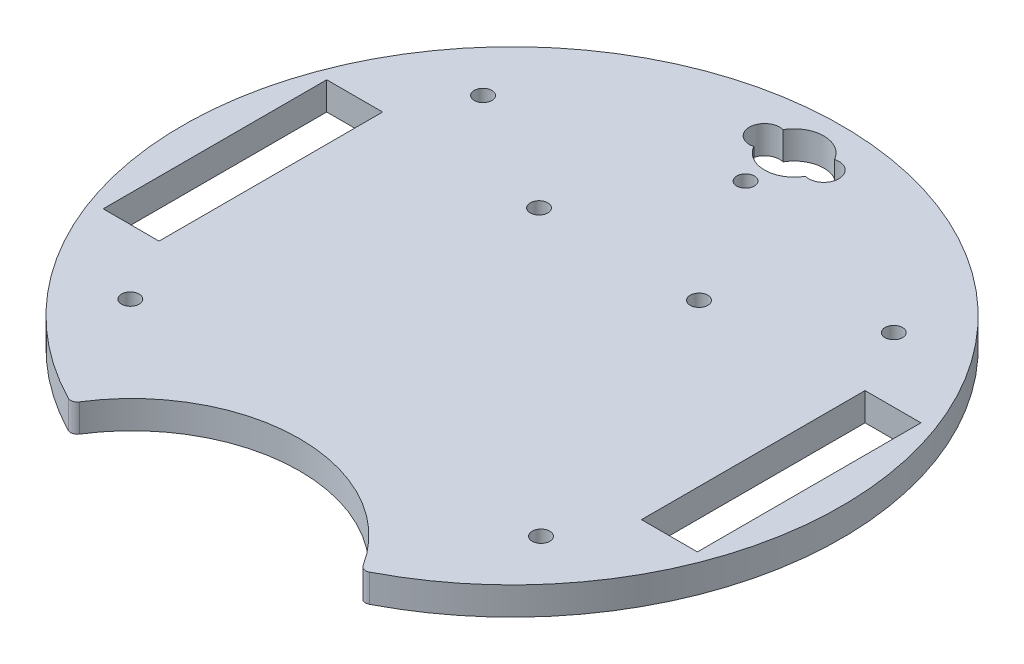
from build123d import *

# Parameters (mm, degrees)
SKETCH1_R           = 2
SKETCH1_W           = 12.7
SKETCH1_H           = 50.8
BOSS_EXTRUDE3_DEPTH = 6.35


with BuildPart() as part:
    # Sketch1 → Boss-Extrude3 (new body)
    with BuildSketch(Plane(origin=(0, 0, 0), x_dir=(1, 0, 0), z_dir=(0, 1, 0))):
        with BuildLine():
            ThreePointArc((34.194833578, -66.63583839), (33.11372382, -66.748004461), (32.240681933, -66.10056535))
            ThreePointArc((32.240681933, -66.10056535), (0, -48.302004425), (-32.240681933, -66.10056535))
            ThreePointArc((-32.240681933, -66.10056535), (-33.11372382, -66.748004461), (-34.194833578, -66.63583839))
            ThreePointArc((-34.194833578, -66.63583839), (0, 74.897407173), (34.194833578, -66.63583839))
        make_face()
        with Locations((0, 53.061187965)):
            Circle(SKETCH1_R, mode=Mode.SUBTRACT)
        with Locations((18.178952795, 24.310551096)):
            Circle(SKETCH1_R, mode=Mode.SUBTRACT)
        with Locations((46.663733983, 40.081231883)):
            Circle(SKETCH1_R, mode=Mode.SUBTRACT)
        with Locations((46.663733983, -40.081231883)):
            Circle(SKETCH1_R, mode=Mode.SUBTRACT)
        with Locations((-46.663733983, -40.081231883)):
            Circle(SKETCH1_R, mode=Mode.SUBTRACT)
        with Locations((-18.178952795, 24.310551096)):
            Circle(SKETCH1_R, mode=Mode.SUBTRACT)
        with Locations((-46.663733983, 40.081231883)):
            Circle(SKETCH1_R, mode=Mode.SUBTRACT)
        with Locations((61.164123727, 0)):
            Rectangle(SKETCH1_W, SKETCH1_H, mode=Mode.SUBTRACT)
        with Locations((-61.164123727, 0)):
            Rectangle(SKETCH1_W, SKETCH1_H, mode=Mode.SUBTRACT)
        with BuildLine():
            ThreePointArc((-5.853899988, 60.78531778), (0.003726822, 57.376699875), (5.857575472, 60.791802193))
            ThreePointArc((5.857575472, 60.791802193), (10.16, 64.107698843), (5.857575472, 67.423595493))
            ThreePointArc((5.857575472, 67.423595493), (0.003726822, 70.838697812), (-5.853899988, 67.430079907))
            ThreePointArc((-5.853899988, 67.430079907), (-10.167207264, 64.107698843), (-5.853899988, 60.78531778))
        make_face(mode=Mode.SUBTRACT)
    extrude(amount=BOSS_EXTRUDE3_DEPTH)


solid = part.part
